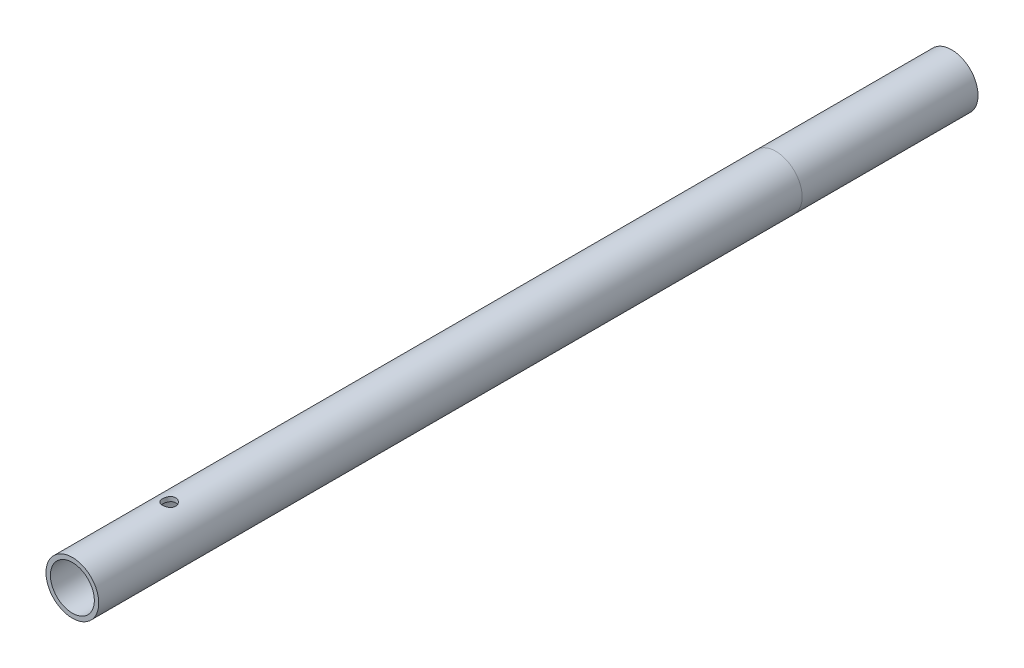
from build123d import *

# Parameters (mm, degrees)
SKETCH1_R               = 6
SKETCH1_R_2             = 5
BOSS_EXTRUDE1_DEPTH     = 200
SKETCH3_R               = 1.5
CUT_EXTRUDE1_DEPTH      = 7
CUT_EXTRUDE1_DEPTH_BACK = 7


with BuildPart() as part:
    # Sketch1 → Boss-Extrude1 (new body)
    with BuildSketch(Plane.XY):
        Circle(SKETCH1_R)
        Circle(SKETCH1_R_2, mode=Mode.SUBTRACT)
    extrude(amount=BOSS_EXTRUDE1_DEPTH)

    # Sketch3 → Cut-Extrude1 (cut, two sides)
    with BuildSketch(Plane(origin=(0, 0, 0), x_dir=(1, 0, 0), z_dir=(0, 1, 0))) as cut_extrude1_sk:
        with Locations((0, -178)):
            Circle(SKETCH3_R)
    extrude(amount=CUT_EXTRUDE1_DEPTH, mode=Mode.SUBTRACT)
    extrude(cut_extrude1_sk.sketch, amount=-CUT_EXTRUDE1_DEPTH_BACK, mode=Mode.SUBTRACT)


solid = part.part
